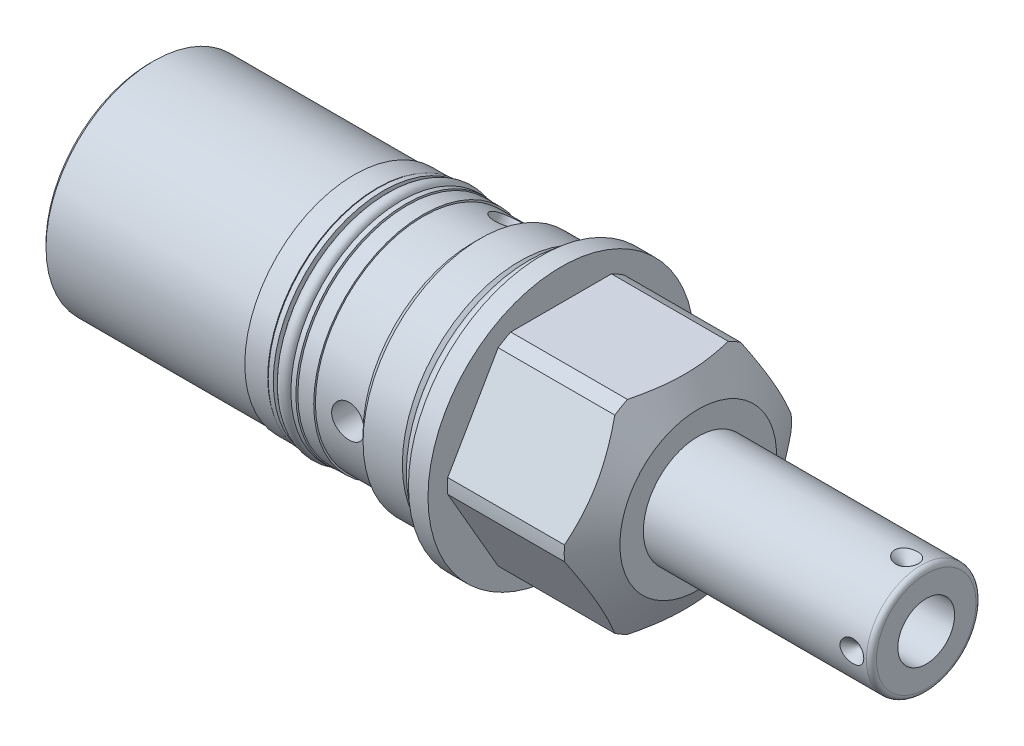
from build123d import *

# Parameters (mm, degrees)
SKETCH1_R           = 26.9875
EXTRUDE1_DEPTH      = 31.75
EXTRUDE1_DEPTH_BACK = 79.375
CUT_EXTRUDE1_REACH  = 81.375
SKETCH2_R           = 26.9875
SKETCH2_R_2         = 23.8125
CUT_EXTRUDE3_REACH  = 31.362
CUT_EXTRUDE3_START  = -0.7874
SKETCH5_R           = 26.9875
CUT_EXTRUDE5_REACH  = 29.788
SKETCH7_R           = 26.9875
SKETCH7_R_2         = 23.0251
SKETCH12_W          = 6.1087
SKETCH12_H          = 2.032
SKETCH14_W          = 0.3429
SKETCH14_H          = 41.402
SKETCH14_H_2        = 10.0076
SKETCH15_R          = 1.4986
SKETCH16_W          = 2.1844
SKETCH16_H          = 1.016
SKETCH17_R          = 1.3081
CIRPATTERN1_COUNT   = 4
CHAMFER1_SIZE       = 0.762
SKETCH23_R          = 3.3147
CUT_EXTRUDE7_DEPTH  = 27.9875
SKETCH26_R          = 3.1369
CUT_EXTRUDE8_DEPTH  = 0.762
SKETCH27_R          = 17.7927
EXTRUDE2_DEPTH      = 0.508
SKETCH28_R          = 3.1369
CUT_EXTRUDE9_DEPTH  = 0.508
CIRPATTERN2_COUNT   = 3


with BuildPart() as part:
    # Sketch1 → Extrude1 (new body, two sides)
    with BuildSketch(Plane(origin=(0, 0, 0), x_dir=(0, 0, -1), z_dir=(1, 0, 0))) as extrude1_sk:
        Circle(SKETCH1_R)
    extrude(amount=EXTRUDE1_DEPTH)
    extrude(extrude1_sk.sketch, amount=-EXTRUDE1_DEPTH_BACK)

    # Sketch2 → Cut-Extrude1 (cut, up to next)
    with BuildSketch(Plane(origin=(0, 0, 0), x_dir=(0, 0, -1), z_dir=(1, 0, 0)), mode=Mode.PRIVATE) as cut_extrude1_sk1:
        Circle(SKETCH2_R)
        Circle(SKETCH2_R_2, mode=Mode.SUBTRACT)
    cut_extrude1_tool1 = extrude(cut_extrude1_sk1.sketch, amount=-CUT_EXTRUDE1_REACH, mode=Mode.PRIVATE) & part.part
    add(cut_extrude1_tool1.solids().sort_by_distance((0, 0, 26.224178))[0], mode=Mode.SUBTRACT)

    # Sketch3 → Cut-Revolve1 (revolve, cut)
    with BuildSketch(Plane.XY, mode=Mode.PRIVATE) as cut_revolve1_sk:
        Polygon((25.334195134, 26.9875), (31.75, 15.875), (31.75, 26.9875), align=None)
    revolve(cut_revolve1_sk.sketch.rotate(Axis((-8.14577342, 0, 0), (1, 0, 0)), 270), axis=Axis((-8.14577342, 0, 0), (1, 0, 0)), mode=Mode.SUBTRACT)  # turned: the seam where the file's is

    # Cut-Extrude3: up to this cone (the profile starts inside it)
    cut_extrude3_end = Plane(origin=(3.9624, 0, 0), z_dir=(-1, 0, 0)).offset(-36.953034523) * Cone(1.732e-06, 230.050244421, 132.819569544, align=(Align.CENTER, Align.CENTER, Align.MIN), mode=Mode.PRIVATE)
    # Sketch5 → Cut-Extrude3 (cut, up to the surface)
    with BuildSketch(Plane.ZY.offset(-3.175).offset(CUT_EXTRUDE3_START), mode=Mode.PRIVATE) as cut_extrude3_sk1:
        with Locations(Location((0, 0, 0), (0, 0, 180))):  # turned: the seam where the file's is
            Circle(SKETCH5_R)
        Polygon((-11.91506618, 20.6375), (11.91506618, 20.6375), (23.830132361, 0), (11.91506618, -20.6375), (-11.91506618, -20.6375), (-23.830132361, 0), align=None, mode=Mode.SUBTRACT)
    cut_extrude3_tool1 = extrude(cut_extrude3_sk1.sketch, amount=-CUT_EXTRUDE3_REACH, mode=Mode.PRIVATE) & cut_extrude3_end
    add(cut_extrude3_tool1.solids().sort_by_distance((3.9624, 0, 26.224178))[0], mode=Mode.SUBTRACT)

    # Cut-Extrude5: up to this cone (the profile starts inside it)
    cut_extrude5_end = Plane(origin=(3.9624, 0, 0), z_dir=(-1, 0, 0)).offset(-36.953034523) * Cone(1.732e-06, 227.32399645, 131.245569544, align=(Align.CENTER, Align.CENTER, Align.MIN), mode=Mode.PRIVATE)
    # Sketch7 → Cut-Extrude5 (cut, up to the surface)
    with BuildSketch(Plane.ZY.offset(-3.9624), mode=Mode.PRIVATE) as cut_extrude5_sk1:
        with Locations(Location((0, 0, 0), (0, 0, 180))):  # turned: the seam where the file's is
            Circle(SKETCH7_R)
        Circle(SKETCH7_R_2, mode=Mode.SUBTRACT)
    cut_extrude5_tool1 = extrude(cut_extrude5_sk1.sketch, amount=-CUT_EXTRUDE5_REACH, mode=Mode.PRIVATE) & cut_extrude5_end
    add(cut_extrude5_tool1.solids().sort_by_distance((3.9624, 0, 26.224178))[0], mode=Mode.SUBTRACT)

    # Sketch9 → Cut-Revolve3 (revolve, cut)
    with BuildSketch(Plane.XY, mode=Mode.PRIVATE) as cut_revolve3_sk:
        Polygon((0, 23.8125), (0, 22.3012), (-2.8956, 22.3012), (-4.4069, 23.8125), align=None)
    revolve(cut_revolve3_sk.sketch.rotate(Axis((-4.4205525, 0, 0), (1, 0, 0)), 90), axis=Axis((-4.4205525, 0, 0), (1, 0, 0)), mode=Mode.SUBTRACT)  # turned: the seam where the file's is

    # Sketch10 → Cut-Revolve4 (revolve, cut)
    with BuildSketch(Plane.XY, mode=Mode.PRIVATE) as cut_revolve4_sk:
        Polygon((-12.3698, 23.8125), (-13.9954, 22.1869), (-79.375, 22.1869), (-79.375, 23.8125), align=None)
    revolve(cut_revolve4_sk.sketch.rotate(Axis((-55.9469925, 0, 0), (1, 0, 0)), 90), axis=Axis((-55.9469925, 0, 0), (1, 0, 0)), mode=Mode.SUBTRACT)  # turned: the seam where the file's is

    # Sketch12 → Cut-Revolve6 (revolve, cut)
    with BuildSketch(Plane.XY, mode=Mode.PRIVATE) as cut_revolve6_sk:
        with Locations((-30.27045, 21.1709)):
            Rectangle(SKETCH12_W, SKETCH12_H)
    revolve(cut_revolve6_sk.sketch.rotate(Axis((-31.750635, 0, 0), (1, 0, 0)), 90), axis=Axis((-31.750635, 0, 0), (1, 0, 0)), mode=Mode.SUBTRACT)  # turned: the seam where the file's is

    # Sketch14 → Cut-Revolve8 (revolve, cut)
    with BuildSketch(Plane(origin=(0, 0, 0), x_dir=(0, -1, 0), z_dir=(0, 0, 1)), mode=Mode.PRIVATE) as cut_revolve8_sk:
        with Locations((22.01545, -58.674)):
            Rectangle(SKETCH14_W, SKETCH14_H)
        with Locations((22.01545, -18.9992)):
            Rectangle(SKETCH14_W, SKETCH14_H_2)
    revolve(cut_revolve8_sk.sketch.rotate(Axis((-55.86603, 0, 0), (1, 0, 0)), 270), axis=Axis((-55.86603, 0, 0), (1, 0, 0)), mode=Mode.SUBTRACT)  # turned: the seam where the file's is

    # Sketch16 → Revolve2 (revolve)
    with BuildSketch(Plane(origin=(0, 0, 0), x_dir=(0, -1, 0), z_dir=(0, 0, 1)), mode=Mode.PRIVATE) as revolve2_sk:
        with Locations((21.2471, -27.9781)):
            Rectangle(SKETCH16_W, SKETCH16_H)
        with Locations((21.2471, -32.5628)):
            Rectangle(SKETCH16_W, SKETCH16_H)
    revolve(revolve2_sk.sketch.rotate(Axis((-31.471235, 0, 0), (1, 0, 0)), 270), axis=Axis((-31.471235, 0, 0), (1, 0, 0)))  # turned: the seam where the file's is

    # S2D0001 → Revolve4 (revolve)
    with BuildSketch(Plane(origin=(0, 0, 0), x_dir=(0, -1, 0), z_dir=(0, 0, 1)), mode=Mode.PRIVATE) as revolve4_sk:
        with BuildLine():
            Line((0, 31.75), (-11.1125, 31.75))
            Line((-11.1125, 31.75), (-11.1125, 76.962))
            ThreePointArc((-11.1125, 76.962), (-10.81492049, 77.68042049), (-10.0965, 77.978))
            Line((-10.0965, 77.978), (0, 77.978))
            Line((0, 77.978), (0, 31.75))
        make_face()
    revolve(revolve4_sk.sketch.rotate(Axis((7.265766347, 0, 0), (1, 0, 0)), 90), axis=Axis((7.265766347, 0, 0), (1, 0, 0)))  # turned: the seam where the file's is

    # Sketch19 → Cut-Revolve9 (revolve, cut)
    with BuildSketch(Plane(origin=(36.322, -2.8067, 0), x_dir=(0, -1, 0), z_dir=(0, 0, 1)), mode=Mode.PRIVATE) as cut_revolve9_sk:
        Polygon((2.9464, 41.656), (2.9464, 24.638), (-2.8067, 21.181188773), (-2.8067, 41.656), align=None)
    revolve(cut_revolve9_sk.sketch.rotate(Axis((17.699325537, 0, 0), (1, 0, 0)), 270), axis=Axis((17.699325537, 0, 0), (1, 0, 0)), mode=Mode.SUBTRACT)  # turned: the seam where the file's is

    # S2D0002 → Cut-Revolve10 (revolve, cut)
    with BuildSketch(Plane(origin=(32.3596, 0, -5.55625), x_dir=(1, 0, 0), z_dir=(0, 1, 0)), mode=Mode.PRIVATE) as cut_revolve10_sk:
        Polygon((41.656, 5.55625), (44.069, 5.55625), (41.656, 3.14325), align=None)
    cut_revolve10 = revolve(cut_revolve10_sk.sketch.rotate(Axis((74.0156, 0, -2.191027232), (0, 0, -1)), 180), axis=Axis((74.0156, 0, -2.191027232), (0, 0, -1)), mode=Mode.SUBTRACT)  # turned: the seam where the file's is

    # CirPattern1: Cut-Revolve10 ×4 about axis
    cirpattern1_axis = Axis((7.265766347, 0, 0), (-1, 0, 0))
    for i in range(1, CIRPATTERN1_COUNT):
        add(cut_revolve10.rotate(cirpattern1_axis, i * 360 / CIRPATTERN1_COUNT), mode=Mode.SUBTRACT)

    # Chamfer1
    chamfer1_edges = [part.edges().sort_by_distance(p)[0] for p in [
        (-79.375, 0, -21.844),
    ]]
    chamfer(chamfer1_edges, length=CHAMFER1_SIZE)

    # Sketch23 → Cut-Extrude7 (cut, through all)
    with BuildSketch(Plane.XY):
        with Locations((-17.399, 0)):
            Circle(SKETCH23_R)
    cut_extrude7 = extrude(amount=CUT_EXTRUDE7_DEPTH, mode=Mode.SUBTRACT)

    # Sketch26 → Cut-Extrude8 (cut)
    with BuildSketch(Plane.ZY.offset(79.375)):
        Circle(SKETCH26_R)
    extrude(amount=-CUT_EXTRUDE8_DEPTH, mode=Mode.SUBTRACT)

    # Sketch27 → Extrude2 (add)
    with BuildSketch(Plane.ZY.offset(79.375)):
        with Locations(Location((0, 0, 0), (0, 0, 180))):  # turned: the seam where the file's is
            Circle(SKETCH27_R)
    extrude(amount=EXTRUDE2_DEPTH)

    # Sketch28 → Cut-Extrude9 (cut)
    with BuildSketch(Plane.ZY.offset(79.883)):
        Circle(SKETCH28_R)
    extrude(amount=-CUT_EXTRUDE9_DEPTH, mode=Mode.SUBTRACT)

    # CirPattern2: Cut-Extrude7 ×3 about axis
    cirpattern2_axis = Axis((7.265766347, 0, 0), (-1, 0, 0))
    for i in range(1, CIRPATTERN2_COUNT):
        add(cut_extrude7.rotate(cirpattern2_axis, i * 360 / CIRPATTERN2_COUNT), mode=Mode.SUBTRACT)


with BuildPart() as body_2:
    # Sketch15 → Revolve1 (revolve)
    with BuildSketch(Plane(origin=(0, 0, 0), x_dir=(0, -1, 0), z_dir=(0, 0, 1)), mode=Mode.PRIVATE) as revolve1_sk:
        with Locations((23.7998, -1.4986)):
            Circle(SKETCH15_R)
    revolve(revolve1_sk.sketch.rotate(Axis((-3.09372, 0, 0), (1, 0, 0)), 270), axis=Axis((-3.09372, 0, 0), (1, 0, 0)))  # turned: the seam where the file's is


with BuildPart() as body_3:
    # Sketch17 → Revolve3 (revolve)
    with BuildSketch(Plane(origin=(0, 0, 0), x_dir=(0, -1, 0), z_dir=(0, 0, 1)), mode=Mode.PRIVATE) as revolve3_sk:
        with Locations((21.463, -30.27045)):
            Circle(SKETCH17_R)
    revolve(revolve3_sk.sketch.rotate(Axis((-31.750635, 0, 0), (1, 0, 0)), 270), axis=Axis((-31.750635, 0, 0), (1, 0, 0)))  # turned: the seam where the file's is


solid = Compound([part.part, body_2.part, body_3.part])
